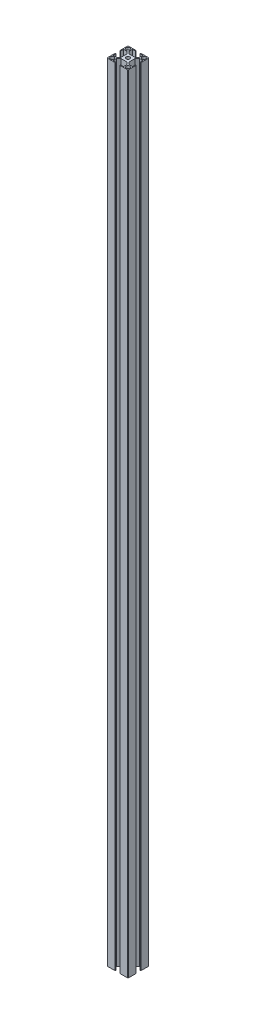
from build123d import *

# Parameters (mm, degrees)
SKETCH1_R           = 3.5
BOSS_EXTRUDE1_DEPTH = 1500
CUT_EXTRUDE1_DEPTH  = 1501


with BuildPart() as part:
    # Sketch1 → Boss-Extrude1 (new body)
    with BuildSketch(Plane(origin=(0, 0, 0), x_dir=(1, 0, 0), z_dir=(0, 1, 0))):
        with BuildLine():
            Line((20, 19), (20, -19))
            ThreePointArc((20, -19), (19.707106781, -19.707106781), (19, -20))
            Line((19, -20), (-19, -20))
            ThreePointArc((-19, -20), (-19.707106781, -19.707106781), (-20, -19))
            Line((-20, -19), (-20, 19))
            ThreePointArc((-20, 19), (-19.707106781, 19.707106781), (-19, 20))
            Line((-19, 20), (19, 20))
            ThreePointArc((19, 20), (19.707106781, 19.707106781), (20, 19))
        make_face()
        with Locations((15.1625, -15.1625)):
            Circle(SKETCH1_R, mode=Mode.SUBTRACT)
        with Locations((-15.1625, -15.1625)):
            Circle(SKETCH1_R, mode=Mode.SUBTRACT)
        with Locations((-15.1625, 15.1625)):
            Circle(SKETCH1_R, mode=Mode.SUBTRACT)
        with Locations((15.1625, 15.1625)):
            Circle(SKETCH1_R, mode=Mode.SUBTRACT)
        Circle(SKETCH1_R, mode=Mode.SUBTRACT)
        Polygon((-10, -18.5), (10, -18.5), (10, -11.825), (5.875, -7.7), (-5.875, -7.7), (-10, -11.825), align=None, mode=Mode.SUBTRACT)
        Polygon((-11.825, -10), (-18.5, -10), (-18.5, 10), (-11.825, 10), (-7.7, 5.875), (-7.7, -5.875), align=None, mode=Mode.SUBTRACT)
        Polygon((-10, 11.825), (-10, 18.5), (10, 18.5), (10, 11.825), (5.875, 7.7), (-5.875, 7.7), align=None, mode=Mode.SUBTRACT)
        Polygon((18.5, -10), (18.5, 10), (11.825, 10), (7.7, 5.875), (7.7, -5.875), (11.825, -10), align=None, mode=Mode.SUBTRACT)
    extrude(amount=BOSS_EXTRUDE1_DEPTH)

    # Sketch2 → Cut-Extrude1 (cut, through all)
    with BuildSketch(Plane(origin=(0, 1500, 0), x_dir=(1, 0, 0), z_dir=(0, 1, 0))):
        with BuildLine():
            Line((-4.65, 20), (-4.65, 19.35))
            ThreePointArc((-4.65, 19.35), (-4.620710678, 19.279289322), (-4.55, 19.25))
            Line((-4.55, 19.25), (-4.25, 19.25))
            ThreePointArc((-4.25, 19.25), (-4.179289322, 19.220710678), (-4.15, 19.15))
            Line((-4.15, 19.15), (-4.15, 18.5))
            Line((-4.15, 18.5), (4.15, 18.5))
            Line((4.15, 18.5), (4.15, 19.15))
            ThreePointArc((4.15, 19.15), (4.179289322, 19.220710678), (4.25, 19.25))
            Line((4.25, 19.25), (4.55, 19.25))
            ThreePointArc((4.55, 19.25), (4.620710678, 19.279289322), (4.65, 19.35))
            Line((4.65, 19.35), (4.65, 20))
            Line((4.65, 20), (-4.65, 20))
        make_face()
        with BuildLine():
            Line((20, 4.65), (19.35, 4.65))
            ThreePointArc((19.35, 4.65), (19.279289322, 4.620710678), (19.25, 4.55))
            Line((19.25, 4.55), (19.25, 4.25))
            ThreePointArc((19.25, 4.25), (19.220710678, 4.179289322), (19.15, 4.15))
            Line((19.15, 4.15), (18.5, 4.15))
            Line((18.5, 4.15), (18.5, -4.15))
            Line((18.5, -4.15), (19.15, -4.15))
            ThreePointArc((19.15, -4.15), (19.220710678, -4.179289322), (19.25, -4.25))
            Line((19.25, -4.25), (19.25, -4.55))
            ThreePointArc((19.25, -4.55), (19.279289322, -4.620710678), (19.35, -4.65))
            Line((19.35, -4.65), (20, -4.65))
            Line((20, -4.65), (20, 4.65))
        make_face()
        with BuildLine():
            Line((4.65, -20), (4.65, -19.35))
            ThreePointArc((4.65, -19.35), (4.620710678, -19.279289322), (4.55, -19.25))
            Line((4.55, -19.25), (4.25, -19.25))
            ThreePointArc((4.25, -19.25), (4.179289322, -19.220710678), (4.15, -19.15))
            Line((4.15, -19.15), (4.15, -18.5))
            Line((4.15, -18.5), (-4.15, -18.5))
            Line((-4.15, -18.5), (-4.15, -19.15))
            ThreePointArc((-4.15, -19.15), (-4.179289322, -19.220710678), (-4.25, -19.25))
            Line((-4.25, -19.25), (-4.55, -19.25))
            ThreePointArc((-4.55, -19.25), (-4.620710678, -19.279289322), (-4.65, -19.35))
            Line((-4.65, -19.35), (-4.65, -20))
            Line((-4.65, -20), (4.65, -20))
        make_face()
        with BuildLine():
            Line((-20, -4.65), (-19.35, -4.65))
            ThreePointArc((-19.35, -4.65), (-19.279289322, -4.620710678), (-19.25, -4.55))
            Line((-19.25, -4.55), (-19.25, -4.25))
            ThreePointArc((-19.25, -4.25), (-19.220710678, -4.179289322), (-19.15, -4.15))
            Line((-19.15, -4.15), (-18.5, -4.15))
            Line((-18.5, -4.15), (-18.5, 4.15))
            Line((-18.5, 4.15), (-19.15, 4.15))
            ThreePointArc((-19.15, 4.15), (-19.220710678, 4.179289322), (-19.25, 4.25))
            Line((-19.25, 4.25), (-19.25, 4.55))
            ThreePointArc((-19.25, 4.55), (-19.279289322, 4.620710678), (-19.35, 4.65))
            Line((-19.35, 4.65), (-20, 4.65))
            Line((-20, 4.65), (-20, -4.65))
        make_face()
    extrude(amount=-CUT_EXTRUDE1_DEPTH, mode=Mode.SUBTRACT)


solid = part.part
